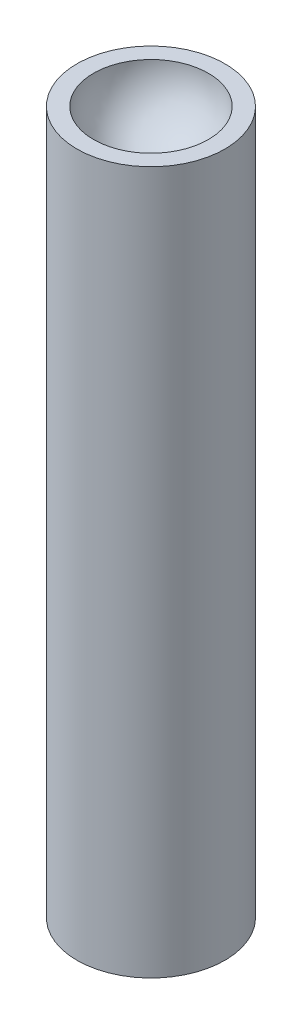
from build123d import *

# Parameters (mm, degrees)
SKETCH1_R           = 2
BOSS_EXTRUDE1_DEPTH = 19


with BuildPart() as part:
    # Sketch1 → Boss-Extrude1 (new body)
    with BuildSketch(Plane(origin=(0, 0, 0), x_dir=(1, 0, 0), z_dir=(0, 1, 0))):
        Circle(SKETCH1_R)
    extrude(amount=BOSS_EXTRUDE1_DEPTH)

    # Sketch3 → Cut-Revolve2 (revolve, cut)
    with BuildSketch(Plane(origin=(0, 19, 0), x_dir=(1, 0, 0), z_dir=(0, 1, 0))):
        with BuildLine():
            Line((0, 1.553467287), (0, -1.553467287))
            ThreePointArc((0, -1.553467287), (-1.553467287, 0), (0, 1.553467287))
        make_face()
    revolve(axis=Axis((0, 19, -1.553467287), (0, 0, 1)), mode=Mode.SUBTRACT)


solid = part.part
